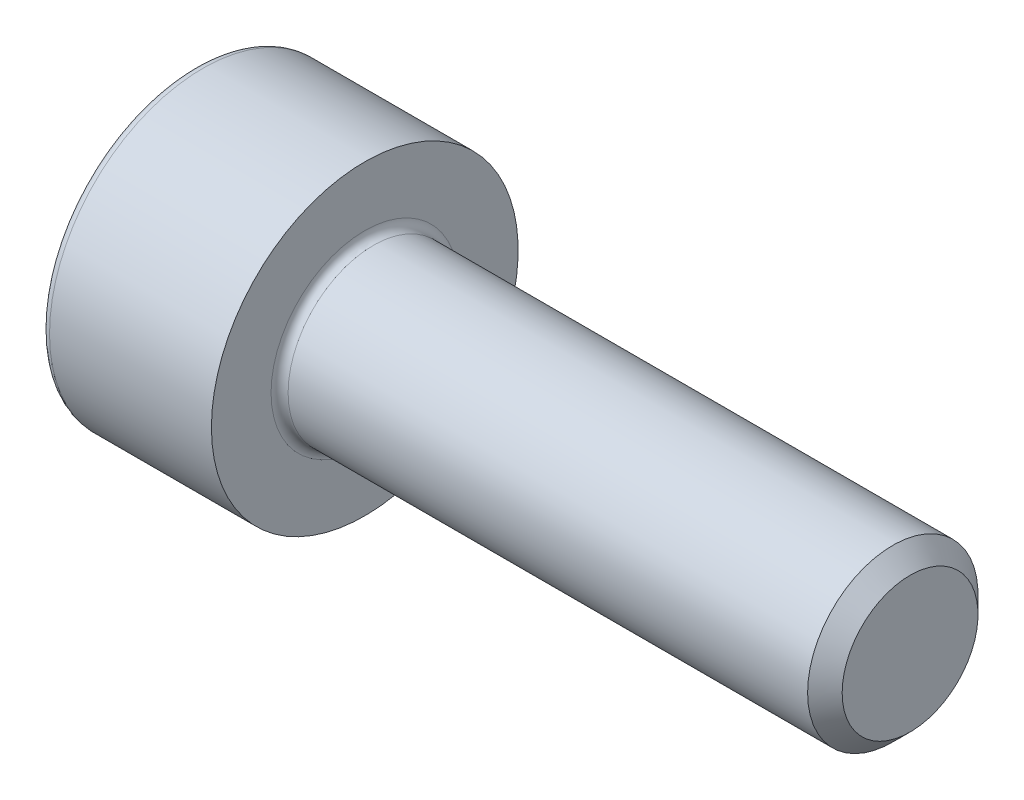
from build123d import *

# Parameters (mm, degrees)
CUT_EXTRUDE1_DEPTH = 1.1


with BuildPart() as part:
    # Sketch1 → Revolve1 (revolve)
    with BuildSketch(Plane.XY):
        with BuildLine():
            Line((7.7465, 1.25), (0.125, 1.25))
            ThreePointArc((0.125, 1.25), (0.036611652, 1.286611652), (0, 1.375))
            Line((0, 1.375), (0, 2.25))
            Line((0, 2.25), (-2.375, 2.25))
            ThreePointArc((-2.375, 2.25), (-2.463388348, 2.213388348), (-2.5, 2.125))
            Line((-2.5, 2.125), (-2.5, 0))
            Line((-2.5, 0), (8, 0))
            Line((8, 0), (8, 0.9965))
            Line((8, 0.9965), (7.7465, 1.25))
        make_face()
    revolve(axis=Axis((-2.5, 0, 0), (1, 0, 0)))

    # Sketch2 → Cut-Extrude1 (cut)
    with BuildSketch(Plane.ZY.offset(2.5)):
        Polygon((1.025, 0.591784026), (0, 1.183568052), (-1.025, 0.591784026), (-1.025, -0.591784026), (0, -1.183568052), (1.025, -0.591784026), align=None)
    extrude(amount=-CUT_EXTRUDE1_DEPTH, mode=Mode.SUBTRACT)


solid = part.part
